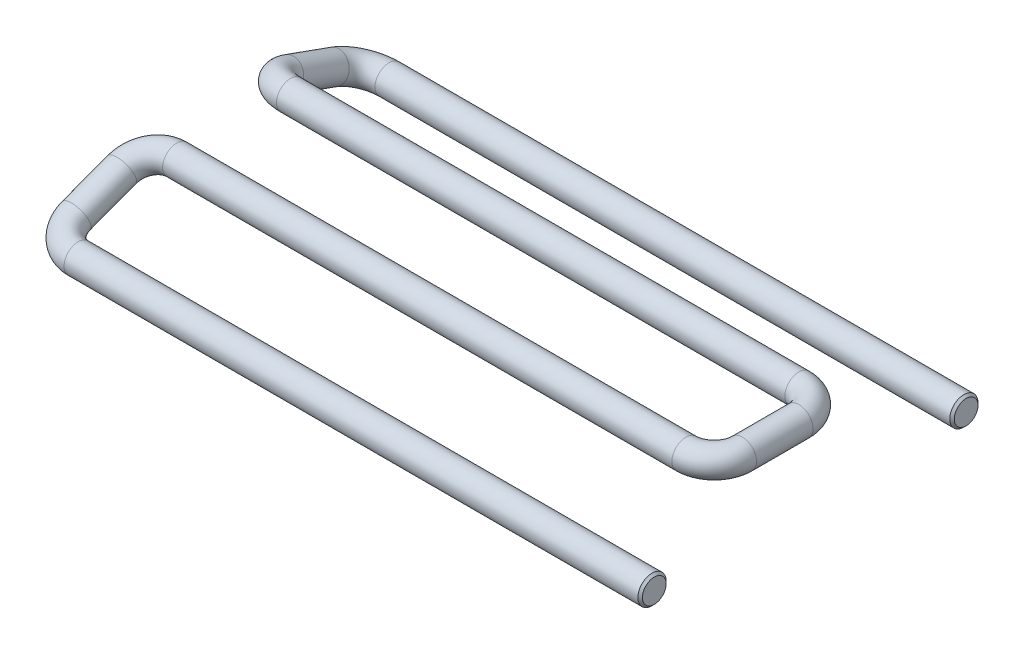
from build123d import *

# Parameters (mm, degrees)
SKETCH1_R     = 1.5875
CHAMFER1_SIZE = 0.254


with BuildPart() as part:
    # Sweep1: sweep along a curve in space
    with BuildLine() as sweep1_path:
        Line((3.194463605, 0, 0), (68.09132068, 0, 0))
        ThreePointArc((3.194463605, 0, 0), (0.942549693, 0.320361628, 0.880326891), (0.019522899, 1.092396461, 3.001813877))
        Line((0.019522899, 1.092396461, 3.001813877), (0.052986653, 2.964848217, 8.147154297))
        ThreePointArc((0.052986653, 2.964848217, 8.147154297), (0.989734174, 3.728303943, 10.245066615), (3.227927359, 4.043973468, 11.1125))
        Line((3.227927359, 4.043973468, 11.1125), (60.397272373, 4.043973468, 11.1125))
        ThreePointArc((60.397272373, 4.043973468, 11.1125), (62.642336404, 4.043973468, 12.04243597), (63.572272373, 4.043973468, 14.2875))
        Line((63.572272373, 4.043973468, 14.2875), (63.572272373, 4.043973468, 20.6375))
        ThreePointArc((63.572272373, 4.043973468, 20.6375), (62.642336404, 4.043973468, 22.88256403), (60.397272373, 4.043973468, 23.8125))
        Line((60.397272373, 4.043973468, 23.8125), (3.122191232, 4.043973468, 23.8125))
        ThreePointArc((3.122191232, 4.043973468, 23.8125), (0.87027732, 3.723611839, 24.692826891), (-0.052749474, 2.951577007, 26.814313877))
        Line((-0.052749474, 2.951577007, 26.814313877), (-0.019285721, 1.079125251, 31.959654297))
        ThreePointArc((-0.019285721, 1.079125251, 31.959654297), (0.9174618, 0.315669525, 34.057566615), (3.155654985, 0, 34.925))
        Line((3.155654985, 0, 34.925), (67.945, 0, 34.925))
    # Sketch1 → Sweep1 (sweep)
    with BuildSketch(Plane(origin=(67.945, 0, 0), x_dir=(0, 0, -1), z_dir=(1, 0, 0))):
        with Locations((-34.925, 0)):
            Circle(SKETCH1_R)
    sweep(path=sweep1_path.line)

    # Chamfer1
    chamfer1_edges = [part.edges().sort_by_distance(p)[0] for p in [
        (68.09132068, 0, -1.5875),
        (67.945, 0, 36.5125),
    ]]
    chamfer(chamfer1_edges, length=CHAMFER1_SIZE)


solid = part.part
